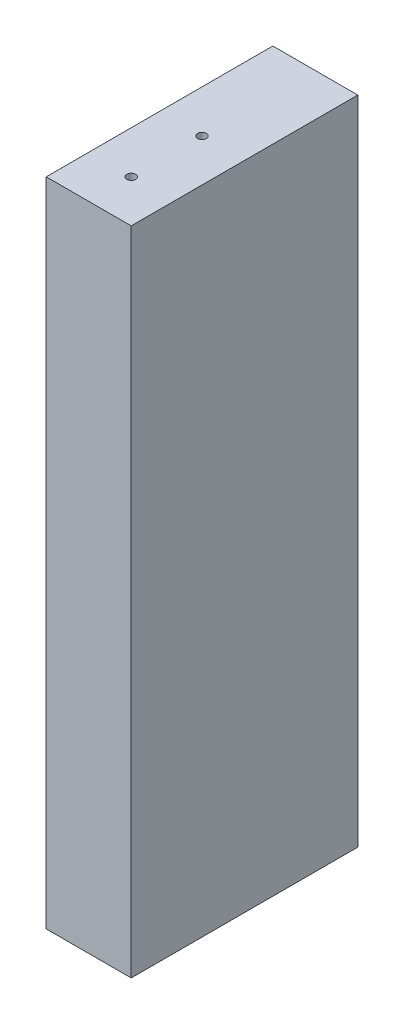
from build123d import *

# Parameters (mm, degrees)
SKETCH1_W                           = 19.05
SKETCH1_H                           = 146.05
BOSS_EXTRUDE1_DEPTH                 = 50.8
F_5_64_0_07813_DIAMETER_HOLE1_D     = 1.984502
F_5_64_0_07813_DIAMETER_HOLE1_DEPTH = 38.1
F_5_64_0_07813_DIAMETER_HOLE1_TIP   = 0.59620455
F_5_64_0_07813_DIAMETER_HOLE2_D     = 1.984502
F_5_64_0_07813_DIAMETER_HOLE2_DEPTH = 38.1
F_5_64_0_07813_DIAMETER_HOLE2_TIP   = 0.59620455
F_5_64_0_07813_DIAMETER_HOLE3_D     = 1.984502
F_5_64_0_07813_DIAMETER_HOLE3_DEPTH = 19.05
F_5_64_0_07813_DIAMETER_HOLE3_TIP   = 0.59620455
F_5_64_0_07813_DIAMETER_HOLE4_D     = 1.984502
F_5_64_0_07813_DIAMETER_HOLE4_DEPTH = 19.05
F_5_64_0_07813_DIAMETER_HOLE4_TIP   = 0.59620455


with BuildPart() as part:
    # Sketch1 → Boss-Extrude1 (new body)
    with BuildSketch(Plane.XY):
        with Locations((472.231312422, 6358.255)):
            Rectangle(SKETCH1_W, SKETCH1_H)
    extrude(amount=BOSS_EXTRUDE1_DEPTH)

    # 5/64 (0.07813) Diameter Hole1
    with Locations(Plane(origin=(0, 1.6e-08, -19.050112211), x_dir=(-1, 0, 0), z_dir=(0, 1e-09, -1))):
        with Locations((-481.589248274, 6993.254992531), (-386.339248274, 6993.254992531), (-291.089248274, 6993.254992531), (-295.274999999, 6965.135938475), (-295.274999999, 6812.735938475), (-295.274999999, 6660.335938474), (-285.166362357, 6631.468843414), (-475.477307398, 6631.468752771), (-485.002307398, 6660.335938474), (-485.002307398, 6812.735938474), (-485.002307398, 6965.135938474), (-478.365617646, 6611.6708), (-287.865617646, 6611.6708), (-307.975, 6564.3379), (-307.975, 6488.1379), (-284.960913066, 6440.805), (-380.210913066, 6440.805), (-475.460913066, 6440.805), (-446.831312422, 6488.1379), (-446.831312422, 6564.3379), (-472.231312422, 6396.355), (-472.231312422, 6320.155), (-472.653156211, 6275.705000839), (-377.403156211, 6275.705000839), (-282.153156211, 6275.705000839), (-282.575, 6320.155), (-282.575, 6396.355), (-435.598646187, 6221.729999816), (-435.598646187, 6145.529999816), (-450.592518112, 6091.554999951), (-460.998646187, 6091.555478285), (-460.998646187, 6056.629999944), (-460.998646187, 5980.429999944), (-460.998646187, 5945.505000042), (-282.153156211, 5945.505000042), (-368.611823093, 5945.505000042)):
            Hole(F_5_64_0_07813_DIAMETER_HOLE1_D / 2, depth=F_5_64_0_07813_DIAMETER_HOLE1_DEPTH)
            with Locations((0, 0, -(F_5_64_0_07813_DIAMETER_HOLE1_DEPTH + F_5_64_0_07813_DIAMETER_HOLE1_TIP / 2))):  # 118° drill point
                Cone(0, F_5_64_0_07813_DIAMETER_HOLE1_D / 2, F_5_64_0_07813_DIAMETER_HOLE1_TIP, mode=Mode.SUBTRACT)

    # 5/64 (0.07813) Diameter Hole2
    with Locations(Plane(origin=(189.656312422, 1.6e-08, -19.050112211), x_dir=(-1, 0, 0), z_dir=(0, 1e-09, -1))):
        with Locations((-481.589248274, 6993.254992531), (-386.339248274, 6993.254992531), (-291.089248274, 6993.254992531), (-295.274999999, 6965.135938475), (-295.274999999, 6812.735938475), (-295.274999999, 6660.335938474), (-285.166362357, 6631.468843414), (-475.477307398, 6631.468752771), (-485.002307398, 6660.335938474), (-485.002307398, 6812.735938474), (-485.002307398, 6965.135938474), (-478.365617646, 6611.6708), (-287.865617646, 6611.6708), (-307.975, 6564.3379), (-307.975, 6488.1379), (-284.960913066, 6440.805), (-380.210913066, 6440.805), (-475.460913066, 6440.805), (-446.831312422, 6488.1379), (-446.831312422, 6564.3379), (-472.231312422, 6396.355), (-472.231312422, 6320.155), (-472.653156211, 6275.705000839), (-377.403156211, 6275.705000839), (-282.153156211, 6275.705000839), (-282.575, 6320.155), (-282.575, 6396.355), (-435.598646187, 6221.729999816), (-435.598646187, 6145.529999816), (-450.592518112, 6091.554999951), (-460.998646187, 6091.555478285), (-460.998646187, 6056.629999944), (-460.998646187, 5980.429999944), (-460.998646187, 5945.505000042), (-282.153156211, 5945.505000042), (-368.611823093, 5945.505000042)):
            Hole(F_5_64_0_07813_DIAMETER_HOLE2_D / 2, depth=F_5_64_0_07813_DIAMETER_HOLE2_DEPTH)
            with Locations((0, 0, -(F_5_64_0_07813_DIAMETER_HOLE2_DEPTH + F_5_64_0_07813_DIAMETER_HOLE2_TIP / 2))):  # 118° drill point
                Cone(0, F_5_64_0_07813_DIAMETER_HOLE2_D / 2, F_5_64_0_07813_DIAMETER_HOLE2_TIP, mode=Mode.SUBTRACT)

    # 5/64 (0.07813) Diameter Hole3
    with Locations(Plane(origin=(0, 6431.28, 0), x_dir=(1, 0, 0), z_dir=(0, 1, 0))):
        with Locations((472.231312422, -41.275), (472.231312422, -25.4)):
            Hole(F_5_64_0_07813_DIAMETER_HOLE3_D / 2, depth=F_5_64_0_07813_DIAMETER_HOLE3_DEPTH)
            with Locations((0, 0, -(F_5_64_0_07813_DIAMETER_HOLE3_DEPTH + F_5_64_0_07813_DIAMETER_HOLE3_TIP / 2))):  # 118° drill point
                Cone(0, F_5_64_0_07813_DIAMETER_HOLE3_D / 2, F_5_64_0_07813_DIAMETER_HOLE3_TIP, mode=Mode.SUBTRACT)

    # 5/64 (0.07813) Diameter Hole4
    with Locations(Plane(origin=(0, 6285.23, 0), x_dir=(-1, 0, 0), z_dir=(0, -1, 0))):
        with Locations((-472.231312422, -25.4), (-472.231312422, -41.275)):
            Hole(F_5_64_0_07813_DIAMETER_HOLE4_D / 2, depth=F_5_64_0_07813_DIAMETER_HOLE4_DEPTH)
            with Locations((0, 0, -(F_5_64_0_07813_DIAMETER_HOLE4_DEPTH + F_5_64_0_07813_DIAMETER_HOLE4_TIP / 2))):  # 118° drill point
                Cone(0, F_5_64_0_07813_DIAMETER_HOLE4_D / 2, F_5_64_0_07813_DIAMETER_HOLE4_TIP, mode=Mode.SUBTRACT)


solid = part.part
